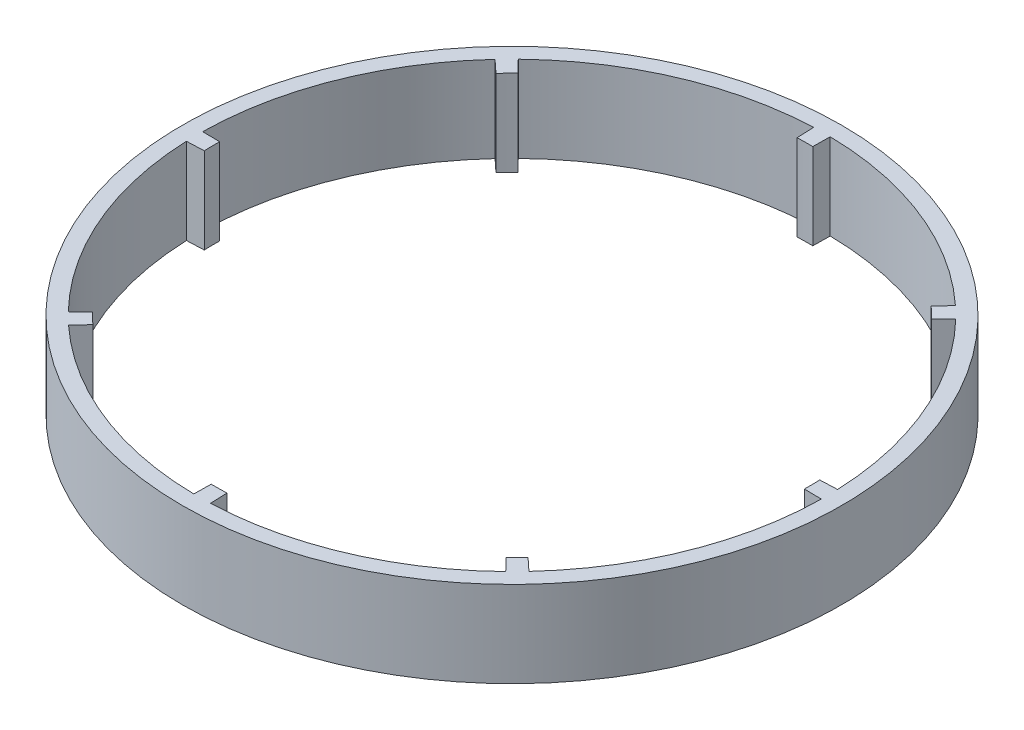
from build123d import *

# Parameters (mm, degrees)
SKETCH1_R           = 115
BOSS_EXTRUDE1_DEPTH = 30


with BuildPart() as part:
    # Sketch1 → Boss-Extrude1 (new body)
    with BuildSketch(Plane(origin=(0, 0, 0), x_dir=(1, 0, 0), z_dir=(0, 1, 0))):
        Circle(SKETCH1_R)
        with BuildLine():
            ThreePointArc((-3.955044182, 103.424405367), (-1.246353574, 103.492495393), (1.463191222, 103.489656833))
            Line((1.463191222, 103.489656833), (1.548013902, 109.489057229))
            ThreePointArc((1.548013902, 109.489057229), (40.682564415, 101.662082177), (74.412877774, 80.330402846))
            Line((74.412877774, 80.330402846), (70.335459814, 75.928736936))
            ThreePointArc((70.335459814, 75.928736936), (72.29894023, 74.061550359), (74.212870565, 72.143605694))
            Line((74.212870565, 72.143605694), (78.51506596, 76.325843705))
            ThreePointArc((78.51506596, 76.325843705), (100.652864871, 43.119030523), (109.420023069, 4.184322106))
            Line((109.420023069, 4.184322106), (103.424405367, 3.955044182))
            ThreePointArc((103.424405367, 3.955044182), (103.481099616, 1.977883277), (103.5, 0))
            ThreePointArc((103.5, 0), (103.497414176, -0.73161389), (103.489656833, -1.463191222))
            Line((103.489656833, -1.463191222), (109.489057229, -1.548013902))
            ThreePointArc((109.489057229, -1.548013902), (101.662082177, -40.682564415), (80.330402846, -74.412877774))
            Line((80.330402846, -74.412877774), (75.928736936, -70.335459814))
            ThreePointArc((75.928736936, -70.335459814), (74.061550359, -72.29894023), (72.143605694, -74.212870565))
            Line((72.143605694, -74.212870565), (76.325843705, -78.51506596))
            ThreePointArc((76.325843705, -78.51506596), (43.119030523, -100.652864871), (4.184322106, -109.420023069))
            Line((4.184322106, -109.420023069), (3.955044182, -103.424405367))
            ThreePointArc((3.955044182, -103.424405367), (1.246353574, -103.492495393), (-1.463191222, -103.489656833))
            Line((-1.463191222, -103.489656833), (-1.548013902, -109.489057229))
            ThreePointArc((-1.548013902, -109.489057229), (-40.682564415, -101.662082177), (-74.412877774, -80.330402846))
            Line((-74.412877774, -80.330402846), (-70.335459814, -75.928736936))
            ThreePointArc((-70.335459814, -75.928736936), (-72.29894023, -74.061550359), (-74.212870565, -72.143605694))
            Line((-74.212870565, -72.143605694), (-78.51506596, -76.325843705))
            ThreePointArc((-78.51506596, -76.325843705), (-100.652864871, -43.119030523), (-109.420023069, -4.184322106))
            Line((-109.420023069, -4.184322106), (-103.424405367, -3.955044182))
            ThreePointArc((-103.424405367, -3.955044182), (-103.492495393, -1.246353574), (-103.489656833, 1.463191222))
            Line((-103.489656833, 1.463191222), (-109.489057229, 1.548013902))
            ThreePointArc((-109.489057229, 1.548013902), (-101.662082177, 40.682564415), (-80.330402846, 74.412877774))
            Line((-80.330402846, 74.412877774), (-75.928736936, 70.335459814))
            ThreePointArc((-75.928736936, 70.335459814), (-74.061550359, 72.29894023), (-72.143605694, 74.212870565))
            Line((-72.143605694, 74.212870565), (-76.325843705, 78.51506596))
            ThreePointArc((-76.325843705, 78.51506596), (-43.119030523, 100.652864871), (-4.184322106, 109.420023069))
            Line((-4.184322106, 109.420023069), (-3.955044182, 103.424405367))
        make_face(mode=Mode.SUBTRACT)
    extrude(amount=BOSS_EXTRUDE1_DEPTH)


solid = part.part
